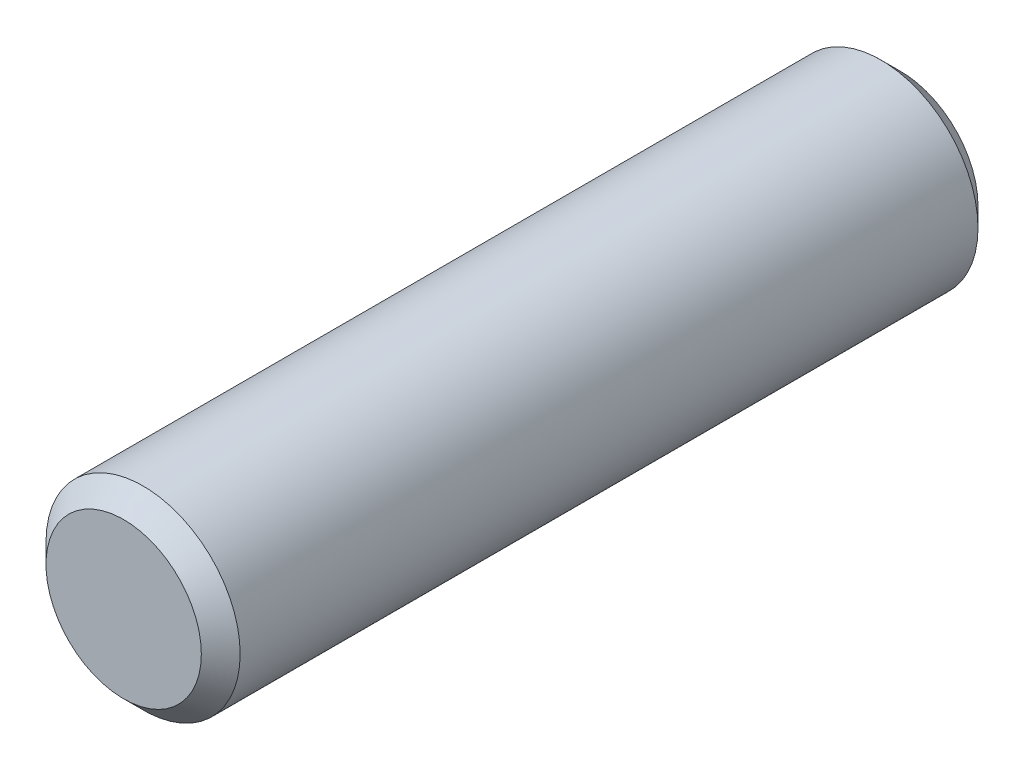
from build123d import *

# Parameters (mm, degrees)
SKETCH1_R           = 1.5
BOSS_EXTRUDE1_DEPTH = 6
CHAMFER1_SIZE       = 0.3


with BuildPart() as part:
    # Sketch1 → Boss-Extrude1 (new body, symmetric)
    with BuildSketch(Plane.XY):
        Circle(SKETCH1_R)
    extrude(amount=BOSS_EXTRUDE1_DEPTH, both=True)

    # Chamfer1
    chamfer1_edges = [part.edges().sort_by_distance(p)[0] for p in [
        (-1.5, 0, -6),
        (-1.5, 0, 6),
    ]]
    chamfer(chamfer1_edges, length=CHAMFER1_SIZE)


solid = part.part
